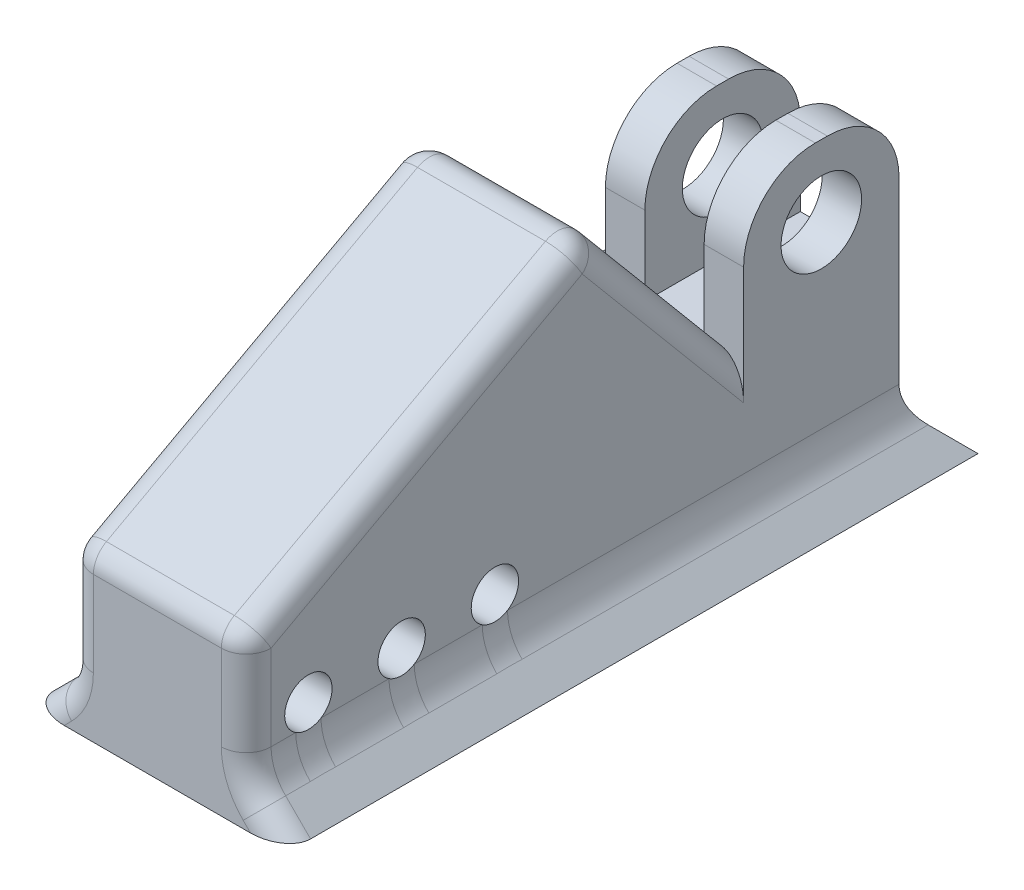
from build123d import *

# Parameters (mm, degrees)
SKETCH1_W                       = 28.58
SKETCH1_H                       = 50
BOSS_EXTRUDE1_DEPTH             = 12.5
SKETCH2_W                       = 9.53
SKETCH2_H                       = 24.225
SKETCH2_W_2                     = 6.35
CUT_EXTRUDE1_DEPTH              = 39.134028111
FILLET1_R                       = 11.53
SKETCH3_R                       = 6.477
CUT_EXTRUDE2_DEPTH              = 40.975822693
BOSS_EXTRUDE2_DEPTH             = 28.58
SKETCH5_W                       = 28.58
SKETCH5_H                       = 25.775
BOSS_EXTRUDE3_DEPTH             = 80
SKETCH6_R                       = 3.81
CUT_EXTRUDE3_DEPTH              = 100.990331533
CUT_EXTRUDE3_DEPTH_BACK         = 100.990331533
BOSS_EXTRUDE4_REACH             = 110.877
BOSS_EXTRUDE4_DIRECTION_2_REACH = 110.877
TROUS_DE_CENTRAGE_5_0MM1_D      = 5
TROUS_DE_CENTRAGE_5_0MM1_DEPTH  = 10
TROUS_DE_CENTRAGE_5_0MM1_TIP    = 1.502151548
BOSS_EXTRU_1_REACH              = 103.987
FILLET2_R                       = 8
FILLET4_R                       = 4


with BuildPart() as part:
    # Sketch1 → Boss-Extrude1 (new, symmetric)
    with BuildSketch(Plane.XY):
        Rectangle(SKETCH1_W, SKETCH1_H)
    extrude(amount=BOSS_EXTRUDE1_DEPTH, both=True)

    # Sketch2 → Cut-Extrude1 (cut, through all)
    with BuildSketch(Plane(origin=(0, 0, 12.5), x_dir=(-1, 0, 0), z_dir=(0, 0, 1))):
        with Locations((-3.175, -12.8875)):
            Rectangle(SKETCH2_W, SKETCH2_H)
        with Locations((11.115, -12.8875)):
            Rectangle(SKETCH2_W_2, SKETCH2_H)
    extrude(amount=-CUT_EXTRUDE1_DEPTH, mode=Mode.SUBTRACT)

    # Fillet1
    fillet1_edges = [part.edges().sort_by_distance(p)[0] for p in [
        (-4.765, 25, -12.5),
        (-4.765, 25, 12.5),
        (11.115, 25, -12.5),
        (11.115, 25, 12.5),
    ]]
    fillet(fillet1_edges, radius=FILLET1_R)

    # Sketch3 → Cut-Extrude2 (cut, through all)
    with BuildSketch(Plane(origin=(14.29, 0, 0), x_dir=(0, 0, -1), z_dir=(1, 0, 0))):
        with Locations(Location((0, 13.47, 0), (0, 0, 270))):
            Circle(SKETCH3_R)
    extrude(amount=-CUT_EXTRUDE2_DEPTH, mode=Mode.SUBTRACT)

    # Sketch4 → Boss-Extrude2 (add)
    with BuildSketch(Plane(origin=(14.29, 0, 0), x_dir=(0, 0, -1), z_dir=(1, 0, 0))):
        Polygon((18.85, -25), (12.5, -18.65), (12.5, -25), align=None)
    extrude(amount=-BOSS_EXTRUDE2_DEPTH)

    # Sketch5 → Boss-Extrude3 (add)
    with BuildSketch(Plane.XY.offset(12.5)):
        with Locations((0, -12.1125)):
            Rectangle(SKETCH5_W, SKETCH5_H)
    extrude(amount=BOSS_EXTRUDE3_DEPTH)

    # Sketch6 → Cut-Extrude3 (cut, two sides)
    with BuildSketch(Plane(origin=(14.29, 0, 0), x_dir=(0, 0, -1), z_dir=(1, 0, 0))) as cut_extrude3_sk:
        with Locations((-82.5, -12.1125)):
            Circle(SKETCH6_R)
        with Locations((-67.5, -12.1125)):
            Circle(SKETCH6_R)
        with Locations((-52.5, -12.1125)):
            Circle(SKETCH6_R)
    extrude(amount=CUT_EXTRUDE3_DEPTH, mode=Mode.SUBTRACT)
    extrude(cut_extrude3_sk.sketch, amount=-CUT_EXTRUDE3_DEPTH_BACK, mode=Mode.SUBTRACT)

    # Boss-Extrude4: up to this face of the body (flat: up to its plane)
    boss_extrude4_end = Plane(part.part.faces().sort_by_distance((0, -12.1125, 92.5))[0])
    # Sketch7 → Boss-Extrude4 (add, up to the picked face)
    with BuildSketch(Plane(origin=(0, 0, -12.5), x_dir=(-1, 0, 0), z_dir=(0, 0, -1)), mode=Mode.PRIVATE) as boss_extrude4_sk1:
        Polygon((-14.29, -25), (-20.64, -25), (-14.29, -18.65), align=None)
    boss_extrude4_tool1 = split(extrude(boss_extrude4_sk1.sketch, amount=-BOSS_EXTRUDE4_REACH, mode=Mode.PRIVATE), bisect_by=boss_extrude4_end, keep=Keep.BOTH, mode=Mode.PRIVATE)
    boss_extrude4 = boss_extrude4_tool1.solids().sort_by(Axis((16.406667, -22.883333, -12.5), (0, 0, 1)))[0]
    add(boss_extrude4)

    # Boss-Extrude4 direction 2: up to this face of the body (flat: up to its plane)
    boss_extrude4_direction_2_end = Plane(part.part.faces().sort_by_distance((0, -21.825, -15.675))[0])
    # Sketch7 → Boss-Extrude4 direction 2 (add, up to the picked face)
    with BuildSketch(Plane(origin=(0, 0, -12.5), x_dir=(-1, 0, 0), z_dir=(0, 0, -1)), mode=Mode.PRIVATE) as boss_extrude4_direction_2_sk1:
        Polygon((-14.29, -25), (-20.64, -25), (-14.29, -18.65), align=None)
    boss_extrude4_direction_2_tool1 = split(extrude(boss_extrude4_direction_2_sk1.sketch, amount=BOSS_EXTRUDE4_DIRECTION_2_REACH, mode=Mode.PRIVATE), bisect_by=boss_extrude4_direction_2_end, keep=Keep.BOTH, mode=Mode.PRIVATE)
    boss_extrude4_direction_2 = boss_extrude4_direction_2_tool1.solids().sort_by(Axis((16.406667, -22.883333, -12.5), (0, 0, -1)))[0]
    add(boss_extrude4_direction_2)

    # Mirror2: Boss-Extrude4, Boss-Extrude4 direction 2 across plane
    add(boss_extrude4.mirror(Plane(origin=(0, 0, 0), x_dir=(0, 0, 1), z_dir=(1, 0, 0))))
    add(boss_extrude4_direction_2.mirror(Plane(origin=(0, 0, 0), x_dir=(0, 0, 1), z_dir=(1, 0, 0))))

    # Trous de centrage Ø5.0mm1
    with Locations(Plane(origin=(0, -25, 0), x_dir=(-1, 0, 0), z_dir=(0, -1, 0))):
        with Locations((-7.5, 0.534345417), (7.5, 0.534345417), (7.5, -14.465654583), (-7.5, -14.465654583), (-7.5, -29.465654583), (7.5, -29.465654583), (7.5, -44.465654583), (-7.5, -44.465654583)):
            Hole(TROUS_DE_CENTRAGE_5_0MM1_D / 2, depth=TROUS_DE_CENTRAGE_5_0MM1_DEPTH)
            with Locations((0, 0, -(TROUS_DE_CENTRAGE_5_0MM1_DEPTH + TROUS_DE_CENTRAGE_5_0MM1_TIP / 2))):  # 118° drill point
                Cone(0, TROUS_DE_CENTRAGE_5_0MM1_D / 2, TROUS_DE_CENTRAGE_5_0MM1_TIP, mode=Mode.SUBTRACT)

    # Boss.-Extru.1: up to this face of the body (flat: up to its plane)
    boss_extru_1_end = Plane(part.part.faces().sort_by_distance((-14.29, -8.709219679, 38.022768873))[0])
    # Esquisse1 → Boss.-Extru.1 (add, up to the picked face)
    with BuildSketch(Plane(origin=(14.29, 0, 0), x_dir=(0, 0, -1), z_dir=(1, 0, 0)), mode=Mode.PRIVATE) as boss_extru_1_sk1:
        Polygon((-37.5, 30.568839815), (-12.5, 0.775), (-92.5, 0.775), align=None)
    boss_extru_1_tool1 = split(extrude(boss_extru_1_sk1.sketch, amount=-BOSS_EXTRU_1_REACH, mode=Mode.PRIVATE), bisect_by=boss_extru_1_end, keep=Keep.BOTH, mode=Mode.PRIVATE)
    add(boss_extru_1_tool1.solids().sort_by(Axis((14.29, 10.70628, 47.5), (-1, 0, 0)))[0])

    # Fillet2
    fillet2_edges = [part.edges().sort_by_distance(p)[0] for p in [
        (14.29, -18.65, 40),
        (-14.29, -18.65, 40),
        (0, -18.65, -12.5),
    ]]
    fillet(fillet2_edges, radius=FILLET2_R)

    # Fillet4
    fillet4_edges = [part.edges().sort_by_distance(p)[0] for p in [
        (18.636572875, -22.996572875, 92.5),
        (-18.636572875, -22.996572875, 92.5),
        (0, 30.568839815, 37.5),
        (14.29, 15.671919907, 65),
        (14.29, 15.671919907, 25),
        (-14.29, 15.671919907, 65),
        (-14.29, 15.671919907, 25),
        (14.29, -7.280645751, 92.5),
        (-14.89896374, -18.39775896, 92.5),
        (14.89896374, -18.39775896, 92.5),
        (-14.29, 0.775, 0),
        (-14.29, -7.280645751, 92.5),
        (0, 0.775, 92.5),
    ]]
    fillet(fillet4_edges, radius=FILLET4_R)


solid = part.part
